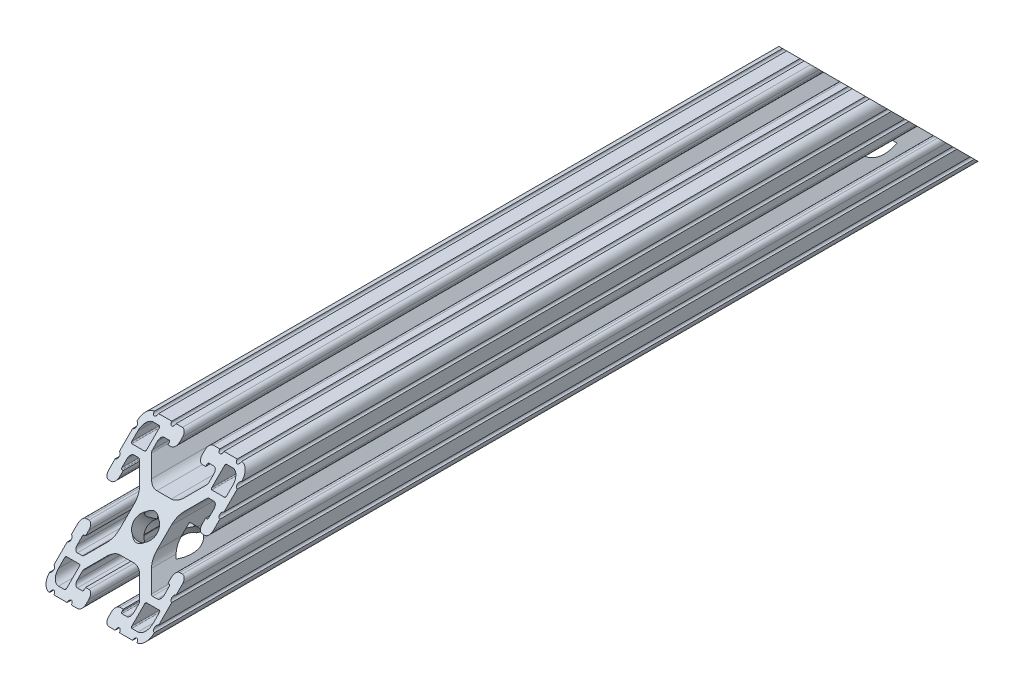
from build123d import *

# Parameters (mm, degrees)
SKETCH1_R          = 3.3274
EXTRUDE1_DEPTH     = 152.4
CUT_EXTRUDE1_DEPTH = 39.1
CUT_EXTRUDE2_START = -6.35
SKETCH3_R          = 4.1656
CUT_EXTRUDE2_DEPTH = 16.764
CUT_EXTRUDE3_START = -6.35
SKETCH4_R          = 9.525
CUT_EXTRUDE3_DEPTH = 37.592


with BuildPart() as part:
    # Sketch1 → Extrude1 (new body)
    with BuildSketch(Plane.XY):
        with BuildLine():
            Line((-15.4432, -6.858), (-14.986, -6.858))
            Line((-14.986, -6.858), (-14.986, -5.6388))
            ThreePointArc((-14.986, -5.6388), (-15.447248241, -4.525248241), (-16.5608, -4.064))
            Line((-16.5608, -4.064), (-17.4752, -4.064))
            ThreePointArc((-17.4752, -4.064), (-18.588751759, -4.525248241), (-19.05, -5.6388))
            Line((-19.05, -5.6388), (-19.05, -7.9756))
            ThreePointArc((-19.05, -7.9756), (-18.288, -8.7376), (-19.05, -9.4996))
            Line((-19.05, -9.4996), (-19.05, -14.3256))
            ThreePointArc((-19.05, -14.3256), (-18.288, -15.0876), (-19.05, -15.8496))
            Line((-19.05, -15.8496), (-19.05, -15.875))
            ThreePointArc((-19.05, -15.875), (-18.12006403, -18.12006403), (-15.875, -19.05))
            Line((-15.875, -19.05), (-15.8496, -19.05))
            ThreePointArc((-15.8496, -19.05), (-15.0876, -18.288), (-14.3256, -19.05))
            Line((-14.3256, -19.05), (-9.4996, -19.05))
            ThreePointArc((-9.4996, -19.05), (-8.7376, -18.288), (-7.9756, -19.05))
            Line((-7.9756, -19.05), (-5.6388, -19.05))
            ThreePointArc((-5.6388, -19.05), (-4.525248241, -18.588751759), (-4.064, -17.4752))
            Line((-4.064, -17.4752), (-4.064, -16.5608))
            ThreePointArc((-4.064, -16.5608), (-4.525248241, -15.447248241), (-5.6388, -14.986))
            Line((-5.6388, -14.986), (-6.858, -14.986))
            Line((-6.858, -14.986), (-6.858, -15.4432))
            ThreePointArc((-6.858, -15.4432), (-6.969592316, -15.712607684), (-7.239, -15.8242))
            Line((-7.239, -15.8242), (-9.017, -15.8242))
            ThreePointArc((-9.017, -15.8242), (-9.915025612, -15.452225612), (-10.287, -14.5542))
            Line((-10.287, -14.5542), (-10.287, -12.810497326))
            ThreePointArc((-10.287, -12.810497326), (-10.219328904, -12.470291755), (-10.026617928, -12.181879398))
            Line((-10.026617928, -12.181879398), (-5.973937506, -8.129198975))
            ThreePointArc((-5.973937506, -8.129198975), (-4.432991483, -7.09957176), (-2.615321716, -6.738014764))
            Line((-2.615321716, -6.738014764), (2.615321716, -6.738014764))
            ThreePointArc((2.615321716, -6.738014764), (4.432991483, -7.09957176), (5.973937506, -8.129198975))
            Line((5.973937506, -8.129198975), (10.026617928, -12.181879398))
            ThreePointArc((10.026617928, -12.181879398), (10.219328904, -12.470291755), (10.287, -12.810497326))
            Line((10.287, -12.810497326), (10.287, -14.5542))
            ThreePointArc((10.287, -14.5542), (9.915025612, -15.452225612), (9.017, -15.8242))
            Line((9.017, -15.8242), (7.239, -15.8242))
            ThreePointArc((7.239, -15.8242), (6.969592316, -15.712607684), (6.858, -15.4432))
            Line((6.858, -15.4432), (6.858, -14.986))
            Line((6.858, -14.986), (5.6388, -14.986))
            ThreePointArc((5.6388, -14.986), (4.525248241, -15.447248241), (4.064, -16.5608))
            Line((4.064, -16.5608), (4.064, -17.4752))
            ThreePointArc((4.064, -17.4752), (4.525248241, -18.588751759), (5.6388, -19.05))
            Line((5.6388, -19.05), (7.9756, -19.05))
            ThreePointArc((7.9756, -19.05), (8.7376, -18.288), (9.4996, -19.05))
            Line((9.4996, -19.05), (14.3256, -19.05))
            ThreePointArc((14.3256, -19.05), (15.0876, -18.288), (15.8496, -19.05))
            Line((15.8496, -19.05), (15.875, -19.05))
            ThreePointArc((15.875, -19.05), (18.12006403, -18.12006403), (19.05, -15.875))
            Line((19.05, -15.875), (19.05, -15.8496))
            ThreePointArc((19.05, -15.8496), (18.288, -15.0876), (19.05, -14.3256))
            Line((19.05, -14.3256), (19.05, -9.4996))
            ThreePointArc((19.05, -9.4996), (18.288, -8.7376), (19.05, -7.9756))
            Line((19.05, -7.9756), (19.05, -5.6388))
            ThreePointArc((19.05, -5.6388), (18.588751759, -4.525248241), (17.4752, -4.064))
            Line((17.4752, -4.064), (16.5608, -4.064))
            ThreePointArc((16.5608, -4.064), (15.447248241, -4.525248241), (14.986, -5.6388))
            Line((14.986, -5.6388), (14.986, -6.858))
            Line((14.986, -6.858), (15.4432, -6.858))
            ThreePointArc((15.4432, -6.858), (15.712607684, -6.969592316), (15.8242, -7.239))
            Line((15.8242, -7.239), (15.8242, -9.017))
            ThreePointArc((15.8242, -9.017), (15.452225612, -9.915025612), (14.5542, -10.287))
            Line((14.5542, -10.287), (12.810497326, -10.287))
            ThreePointArc((12.810497326, -10.287), (12.470291755, -10.219328904), (12.181879398, -10.026617928))
            Line((12.181879398, -10.026617928), (8.129198975, -5.973937506))
            ThreePointArc((8.129198975, -5.973937506), (7.09957176, -4.432991483), (6.738014764, -2.615321716))
            Line((6.738014764, -2.615321716), (6.738014764, 2.615321716))
            ThreePointArc((6.738014764, 2.615321716), (7.09957176, 4.432991483), (8.129198975, 5.973937506))
            Line((8.129198975, 5.973937506), (12.181879398, 10.026617928))
            ThreePointArc((12.181879398, 10.026617928), (12.470291755, 10.219328904), (12.810497326, 10.287))
            Line((12.810497326, 10.287), (14.5542, 10.287))
            ThreePointArc((14.5542, 10.287), (15.452225612, 9.915025612), (15.8242, 9.017))
            Line((15.8242, 9.017), (15.8242, 7.239))
            ThreePointArc((15.8242, 7.239), (15.712607684, 6.969592316), (15.4432, 6.858))
            Line((15.4432, 6.858), (14.986, 6.858))
            Line((14.986, 6.858), (14.986, 5.6388))
            ThreePointArc((14.986, 5.6388), (15.447248241, 4.525248241), (16.5608, 4.064))
            Line((16.5608, 4.064), (17.4752, 4.064))
            ThreePointArc((17.4752, 4.064), (18.588751759, 4.525248241), (19.05, 5.6388))
            Line((19.05, 5.6388), (19.05, 7.9756))
            ThreePointArc((19.05, 7.9756), (18.288, 8.7376), (19.05, 9.4996))
            Line((19.05, 9.4996), (19.05, 14.3256))
            ThreePointArc((19.05, 14.3256), (18.288, 15.0876), (19.05, 15.8496))
            Line((19.05, 15.8496), (19.05, 15.875))
            ThreePointArc((19.05, 15.875), (18.12006403, 18.12006403), (15.875, 19.05))
            Line((15.875, 19.05), (15.8496, 19.05))
            ThreePointArc((15.8496, 19.05), (15.0876, 18.288), (14.3256, 19.05))
            Line((14.3256, 19.05), (9.4996, 19.05))
            ThreePointArc((9.4996, 19.05), (8.7376, 18.288), (7.9756, 19.05))
            Line((7.9756, 19.05), (5.6388, 19.05))
            ThreePointArc((5.6388, 19.05), (4.525248241, 18.588751759), (4.064, 17.4752))
            Line((4.064, 17.4752), (4.064, 16.5608))
            ThreePointArc((4.064, 16.5608), (4.525248241, 15.447248241), (5.6388, 14.986))
            Line((5.6388, 14.986), (6.858, 14.986))
            Line((6.858, 14.986), (6.858, 15.4432))
            ThreePointArc((6.858, 15.4432), (6.969592316, 15.712607684), (7.239, 15.8242))
            Line((7.239, 15.8242), (9.017, 15.8242))
            ThreePointArc((9.017, 15.8242), (9.915025612, 15.452225612), (10.287, 14.5542))
            Line((10.287, 14.5542), (10.287, 12.810497326))
            ThreePointArc((10.287, 12.810497326), (10.219328904, 12.470291755), (10.026617928, 12.181879398))
            Line((10.026617928, 12.181879398), (5.973937506, 8.129198975))
            ThreePointArc((5.973937506, 8.129198975), (4.432991483, 7.09957176), (2.615321716, 6.738014764))
            Line((2.615321716, 6.738014764), (-2.615321716, 6.738014764))
            ThreePointArc((-2.615321716, 6.738014764), (-4.432991483, 7.09957176), (-5.973937506, 8.129198975))
            Line((-5.973937506, 8.129198975), (-10.026617928, 12.181879398))
            ThreePointArc((-10.026617928, 12.181879398), (-10.219328904, 12.470291755), (-10.287, 12.810497326))
            Line((-10.287, 12.810497326), (-10.287, 14.5542))
            ThreePointArc((-10.287, 14.5542), (-9.915025612, 15.452225612), (-9.017, 15.8242))
            Line((-9.017, 15.8242), (-7.239, 15.8242))
            ThreePointArc((-7.239, 15.8242), (-6.969592316, 15.712607684), (-6.858, 15.4432))
            Line((-6.858, 15.4432), (-6.858, 14.986))
            Line((-6.858, 14.986), (-5.6388, 14.986))
            ThreePointArc((-5.6388, 14.986), (-4.525248241, 15.447248241), (-4.064, 16.5608))
            Line((-4.064, 16.5608), (-4.064, 17.4752))
            ThreePointArc((-4.064, 17.4752), (-4.525248241, 18.588751759), (-5.6388, 19.05))
            Line((-5.6388, 19.05), (-7.9756, 19.05))
            ThreePointArc((-7.9756, 19.05), (-8.7376, 18.288), (-9.4996, 19.05))
            Line((-9.4996, 19.05), (-14.3256, 19.05))
            ThreePointArc((-14.3256, 19.05), (-15.0876, 18.288), (-15.8496, 19.05))
            Line((-15.8496, 19.05), (-15.875, 19.05))
            ThreePointArc((-15.875, 19.05), (-18.12006403, 18.12006403), (-19.05, 15.875))
            Line((-19.05, 15.875), (-19.05, 15.8496))
            ThreePointArc((-19.05, 15.8496), (-18.288, 15.0876), (-19.05, 14.3256))
            Line((-19.05, 14.3256), (-19.05, 9.4996))
            ThreePointArc((-19.05, 9.4996), (-18.288, 8.7376), (-19.05, 7.9756))
            Line((-19.05, 7.9756), (-19.05, 5.6388))
            ThreePointArc((-19.05, 5.6388), (-18.588751759, 4.525248241), (-17.4752, 4.064))
            Line((-17.4752, 4.064), (-16.5608, 4.064))
            ThreePointArc((-16.5608, 4.064), (-15.447248241, 4.525248241), (-14.986, 5.6388))
            Line((-14.986, 5.6388), (-14.986, 6.858))
            Line((-14.986, 6.858), (-15.4432, 6.858))
            ThreePointArc((-15.4432, 6.858), (-15.712607684, 6.969592316), (-15.8242, 7.239))
            Line((-15.8242, 7.239), (-15.8242, 9.017))
            ThreePointArc((-15.8242, 9.017), (-15.452225612, 9.915025612), (-14.5542, 10.287))
            Line((-14.5542, 10.287), (-12.810497326, 10.287))
            ThreePointArc((-12.810497326, 10.287), (-12.470291755, 10.219328904), (-12.181879398, 10.026617928))
            Line((-12.181879398, 10.026617928), (-8.129198975, 5.973937506))
            ThreePointArc((-8.129198975, 5.973937506), (-7.09957176, 4.432991483), (-6.738014764, 2.615321716))
            Line((-6.738014764, 2.615321716), (-6.738014764, -2.615321716))
            ThreePointArc((-6.738014764, -2.615321716), (-7.09957176, -4.432991483), (-8.129198975, -5.973937506))
            Line((-8.129198975, -5.973937506), (-12.181879398, -10.026617928))
            ThreePointArc((-12.181879398, -10.026617928), (-12.470291755, -10.219328904), (-12.810497326, -10.287))
            Line((-12.810497326, -10.287), (-14.5542, -10.287))
            ThreePointArc((-14.5542, -10.287), (-15.452225612, -9.915025612), (-15.8242, -9.017))
            Line((-15.8242, -9.017), (-15.8242, -7.239))
            ThreePointArc((-15.8242, -7.239), (-15.712607684, -6.969592316), (-15.4432, -6.858))
        make_face()
        Circle(SKETCH1_R, mode=Mode.SUBTRACT)
        with BuildLine():
            Line((16.8656, 11.8618), (12.2428, 11.8618))
            ThreePointArc((12.2428, 11.8618), (11.973392316, 11.973392316), (11.8618, 12.2428))
            Line((11.8618, 12.2428), (11.8618, 16.8656))
            ThreePointArc((11.8618, 16.8656), (11.973392316, 17.135007684), (12.2428, 17.2466))
            Line((12.2428, 17.2466), (14.4526, 17.2466))
            ThreePointArc((14.4526, 17.2466), (16.428256347, 16.428256347), (17.2466, 14.4526))
            Line((17.2466, 14.4526), (17.2466, 12.2428))
            ThreePointArc((17.2466, 12.2428), (17.135007684, 11.973392316), (16.8656, 11.8618))
        make_face(mode=Mode.SUBTRACT)
        with BuildLine():
            Line((-16.8656, -11.8618), (-12.2428, -11.8618))
            ThreePointArc((-12.2428, -11.8618), (-11.973392316, -11.973392316), (-11.8618, -12.2428))
            Line((-11.8618, -12.2428), (-11.8618, -16.8656))
            ThreePointArc((-11.8618, -16.8656), (-11.973392316, -17.135007684), (-12.2428, -17.2466))
            Line((-12.2428, -17.2466), (-14.4526, -17.2466))
            ThreePointArc((-14.4526, -17.2466), (-16.428256347, -16.428256347), (-17.2466, -14.4526))
            Line((-17.2466, -14.4526), (-17.2466, -12.2428))
            ThreePointArc((-17.2466, -12.2428), (-17.135007684, -11.973392316), (-16.8656, -11.8618))
        make_face(mode=Mode.SUBTRACT)
        with BuildLine():
            Line((11.8618, -16.8656), (11.8618, -12.2428))
            ThreePointArc((11.8618, -12.2428), (11.973392316, -11.973392316), (12.2428, -11.8618))
            Line((12.2428, -11.8618), (16.8656, -11.8618))
            ThreePointArc((16.8656, -11.8618), (17.135007684, -11.973392316), (17.2466, -12.2428))
            Line((17.2466, -12.2428), (17.2466, -14.4526))
            ThreePointArc((17.2466, -14.4526), (16.428256347, -16.428256347), (14.4526, -17.2466))
            Line((14.4526, -17.2466), (12.2428, -17.2466))
            ThreePointArc((12.2428, -17.2466), (11.973392316, -17.135007684), (11.8618, -16.8656))
        make_face(mode=Mode.SUBTRACT)
        with BuildLine():
            Line((-11.8618, 16.8656), (-11.8618, 12.2428))
            ThreePointArc((-11.8618, 12.2428), (-11.973392316, 11.973392316), (-12.2428, 11.8618))
            Line((-12.2428, 11.8618), (-16.8656, 11.8618))
            ThreePointArc((-16.8656, 11.8618), (-17.135007684, 11.973392316), (-17.2466, 12.2428))
            Line((-17.2466, 12.2428), (-17.2466, 14.4526))
            ThreePointArc((-17.2466, 14.4526), (-16.428256347, 16.428256347), (-14.4526, 17.2466))
            Line((-14.4526, 17.2466), (-12.2428, 17.2466))
            ThreePointArc((-12.2428, 17.2466), (-11.973392316, 17.135007684), (-11.8618, 16.8656))
        make_face(mode=Mode.SUBTRACT)
    extrude1 = extrude(amount=-EXTRUDE1_DEPTH)

    # Sketch2 → Cut-Extrude1 (cut, through all)
    with BuildSketch(Plane(origin=(19.05, 0, 0), x_dir=(0, 0, -1), z_dir=(1, 0, 0))):
        Polygon((0, -19.05), (0, 27.880063074), (46.930063074, 27.880063074), align=None)
    cut_extrude1 = extrude(amount=-CUT_EXTRUDE1_DEPTH, mode=Mode.SUBTRACT)

    # Sketch3 → Cut-Extrude2 (cut)
    with BuildSketch(Plane(origin=(0, -9.525, -9.525), x_dir=(1, 0, 0), z_dir=(0, 0.707106781, 0.707106781)).offset(CUT_EXTRUDE2_START)):
        with Locations((0, 13.470384182)):
            Circle(SKETCH3_R)
    cut_extrude2 = extrude(amount=CUT_EXTRUDE2_DEPTH, mode=Mode.SUBTRACT)

    # Sketch4 → Cut-Extrude3 (cut)
    with BuildSketch(Plane(origin=(0, -9.525, -9.525), x_dir=(1, 0, 0), z_dir=(0, 0.707106781, 0.707106781)).offset(CUT_EXTRUDE3_START)):
        with Locations((0, 13.470384182)):
            Circle(SKETCH4_R)
    cut_extrude3 = extrude(amount=-CUT_EXTRUDE3_DEPTH, mode=Mode.SUBTRACT)

    # Mirror1: Extrude1, Cut-Extrude1, Cut-Extrude2, Cut-Extrude3 across plane
    add(extrude1.mirror(Plane(origin=(-15.4432, -7.239, -152.4), x_dir=(1, 0, 0), z_dir=(0, 0, 1))))
    add(cut_extrude1.mirror(Plane(origin=(-15.4432, -7.239, -152.4), x_dir=(1, 0, 0), z_dir=(0, 0, 1))), mode=Mode.SUBTRACT)
    add(cut_extrude2.mirror(Plane(origin=(-15.4432, -7.239, -152.4), x_dir=(1, 0, 0), z_dir=(0, 0, 1))), mode=Mode.SUBTRACT)
    add(cut_extrude3.mirror(Plane(origin=(-15.4432, -7.239, -152.4), x_dir=(1, 0, 0), z_dir=(0, 0, 1))), mode=Mode.SUBTRACT)


solid = part.part
